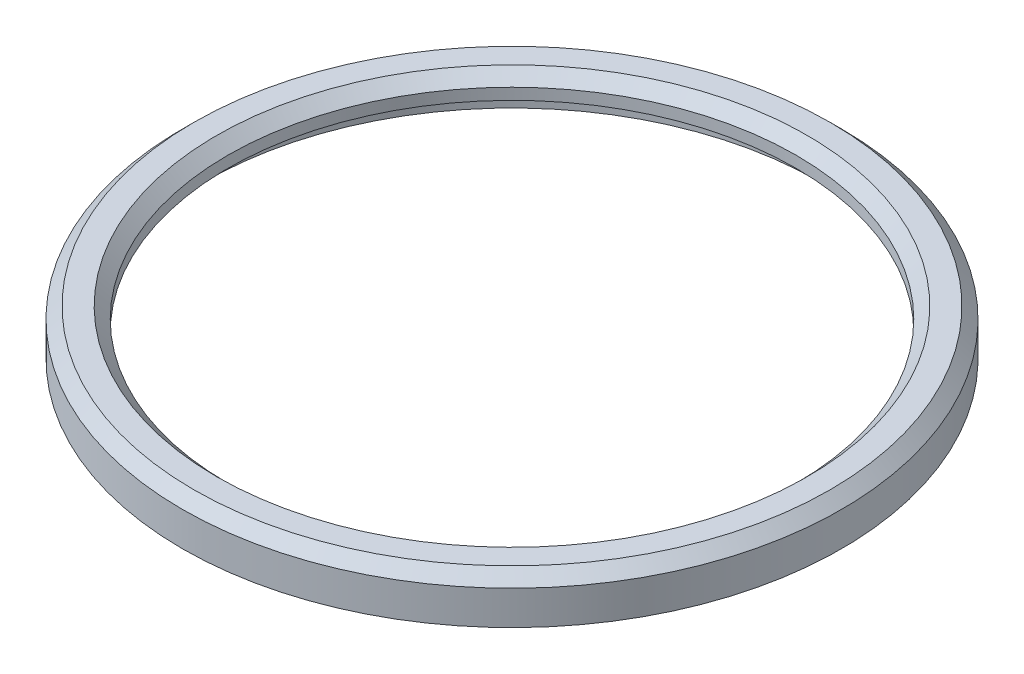
from build123d import *

# Parameters (mm, degrees)
SKETCH1_R           = 14.5
SKETCH1_R_2         = 12.5
BOSS_EXTRUDE1_DEPTH = 2
SKETCH2_R           = 13.5
CUT_EXTRUDE1_DEPTH  = 1
CHAMFER1_SIZE       = 0.5


with BuildPart() as part:
    # Sketch1 → Boss-Extrude1 (new body)
    with BuildSketch(Plane(origin=(0, 0, 0), x_dir=(1, 0, 0), z_dir=(0, 1, 0))):
        Circle(SKETCH1_R)
        Circle(SKETCH1_R_2, mode=Mode.SUBTRACT)
    extrude(amount=BOSS_EXTRUDE1_DEPTH)

    # Sketch2 → Cut-Extrude1 (cut)
    with BuildSketch(Plane.XZ):
        Circle(SKETCH2_R)
    extrude(amount=-CUT_EXTRUDE1_DEPTH, mode=Mode.SUBTRACT)

    # Chamfer1
    chamfer1_edges = [part.edges().sort_by_distance(p)[0] for p in [
        (-14.5, 2, 0),
        (-12.5, 2, 0),
    ]]
    chamfer(chamfer1_edges, length=CHAMFER1_SIZE)


solid = part.part
